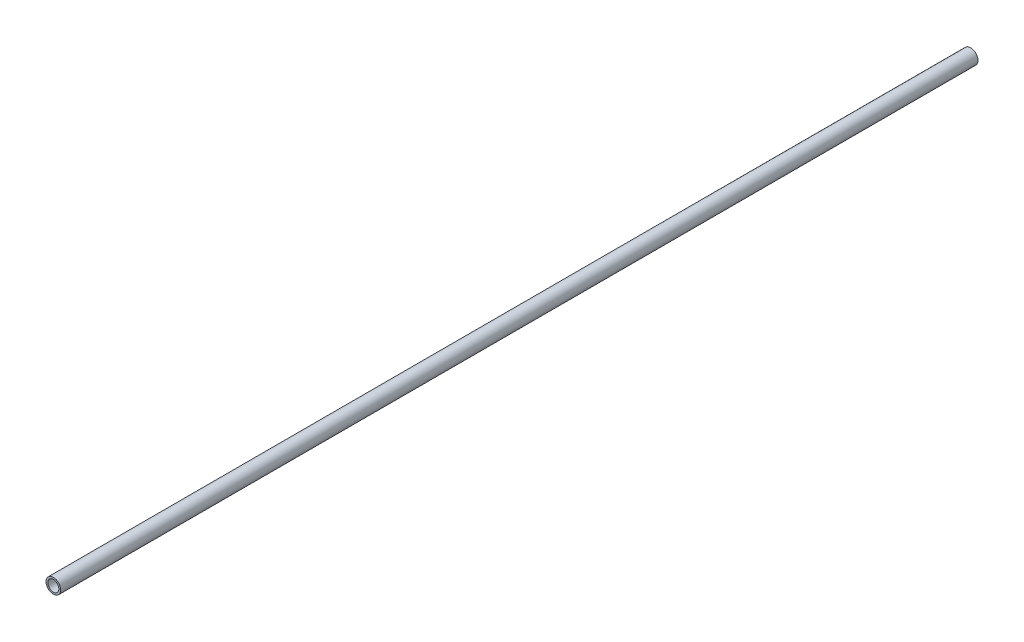
from build123d import *

# Parameters (mm, degrees)
SKETCH_1_R      = 4
SKETCH_1_R_2    = 3
EXTRUDE_1_DEPTH = 250


with BuildPart() as part:
    # Эскиз1 → Бобышка-Вытянуть1 (new body, symmetric)
    with BuildSketch(Plane.XY):
        Circle(SKETCH_1_R)
        Circle(SKETCH_1_R_2, mode=Mode.SUBTRACT)
    extrude(amount=EXTRUDE_1_DEPTH, both=True)


solid = part.part
